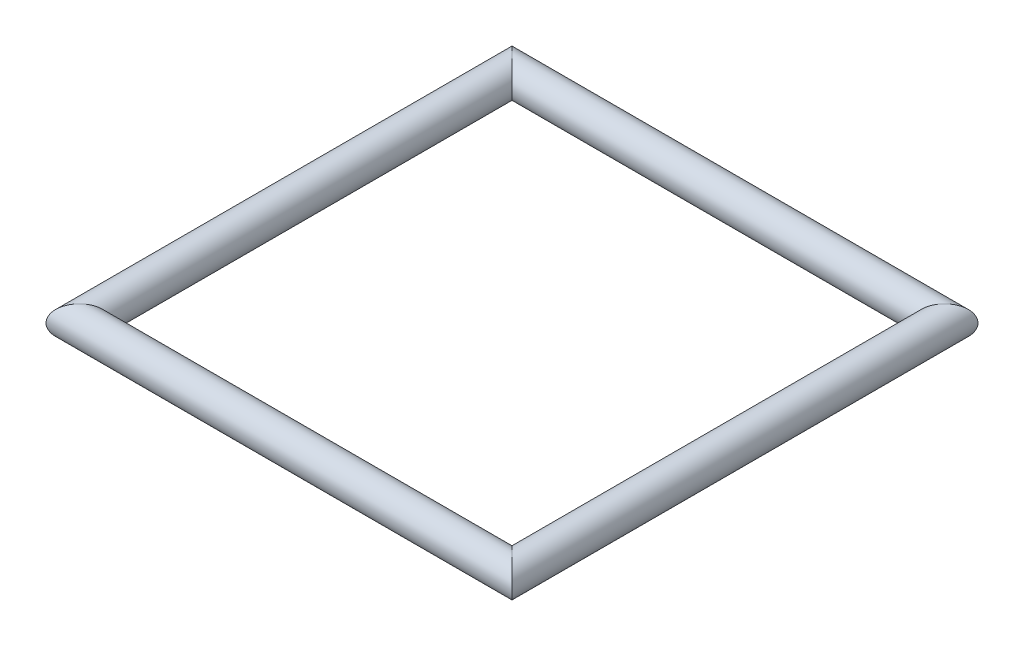
from build123d import *

# Parameters (mm, degrees)
SWEEP1_PROFILE_R = 50


with BuildPart() as part:
    # Sweep1: sweep along a path in Sketch1
    with BuildLine(Plane(origin=(0, 0, 0), x_dir=(1, 0, 0), z_dir=(0, 1, 0))) as sweep1_path:
        Line((-650, 650), (650, 650))
        Line((650, 650), (650, -650))
        Line((650, -650), (-650, -650))
        Line((-650, -650), (-650, 650))
    # Sweep1 profile (on start of the path) → Sweep1 (sweep)
    with BuildSketch(Plane(origin=(-650, 0, -650), x_dir=(0, 0, 1), z_dir=(1, 0, 0))):
        Circle(SWEEP1_PROFILE_R)
    sweep(path=sweep1_path.line, transition=Transition.RIGHT)


solid = part.part
